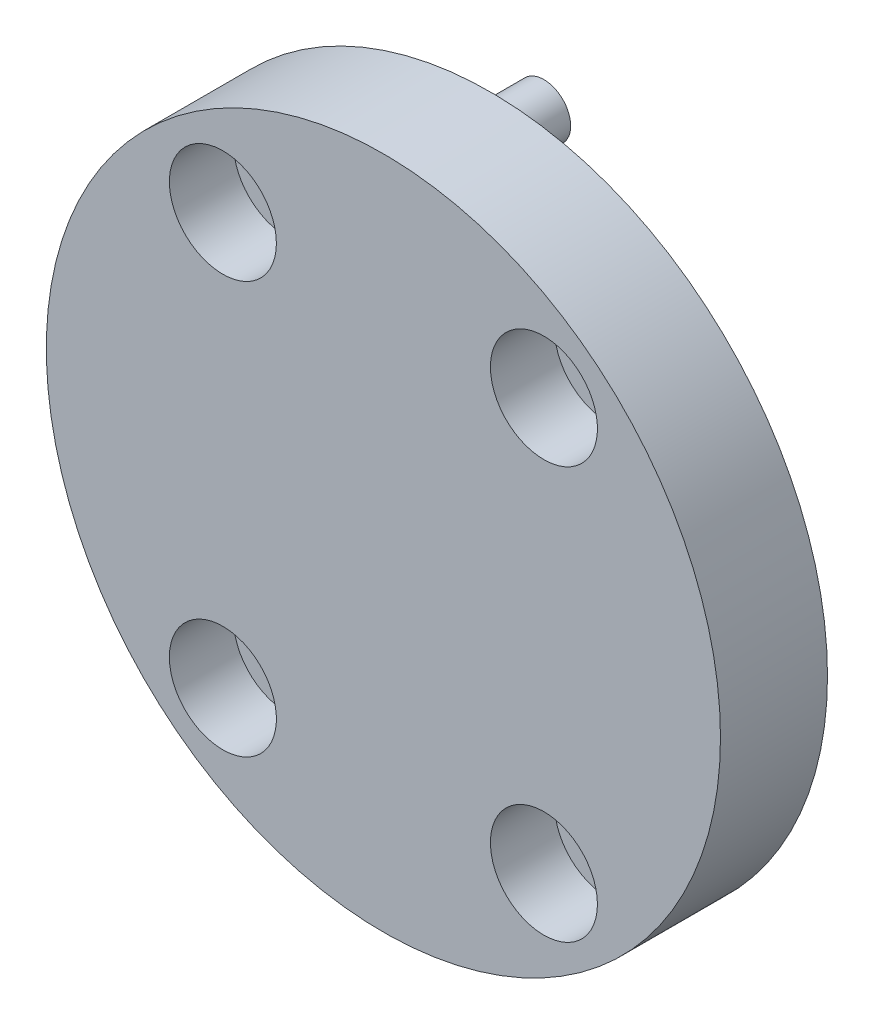
from build123d import *

# Parameters (mm, degrees)
SKETCH1_R           = 31.5
BOSS_EXTRUDE1_DEPTH = 5
SKETCH2_R           = 3
CUT_EXTRUDE1_DEPTH  = 46.656324863
SKETCH2_4_R         = 2.5
BOSS_EXTRUDE2_DEPTH = 15
SKETCH2_5_R         = 5
CUT_EXTRUDE2_DEPTH  = 6


with BuildPart() as part:
    # Sketch1 → Boss-Extrude1 (new, symmetric)
    with BuildSketch(Plane.XY):
        Circle(SKETCH1_R)
    extrude(amount=BOSS_EXTRUDE1_DEPTH, both=True)

    # Sketch2 → Cut-Extrude1 (cut, through all)
    with BuildSketch(Plane.XY.offset(5)):
        with Locations((-15, 19.242640687)):
            Circle(SKETCH2_R)
        with Locations((-15, -19.242640687)):
            Circle(SKETCH2_R)
        with Locations((15, -19.242640687)):
            Circle(SKETCH2_R)
        with Locations((15, 19.242640687)):
            Circle(SKETCH2_R)
    extrude(amount=-CUT_EXTRUDE1_DEPTH, mode=Mode.SUBTRACT)

    # Sketch2_4 → Boss-Extrude2 (add)
    with BuildSketch(Plane.XY.offset(5)):
        with Locations((0, 27.5)):
            Circle(SKETCH2_4_R)
    extrude(amount=-BOSS_EXTRUDE2_DEPTH)

    # Sketch2_5 → Cut-Extrude2 (cut)
    with BuildSketch(Plane.XY.offset(5)):
        with Locations((-15, 19.242640687)):
            Circle(SKETCH2_5_R)
        with Locations((-15, -19.242640687)):
            Circle(SKETCH2_5_R)
        with Locations((15, -19.242640687)):
            Circle(SKETCH2_5_R)
        with Locations((15, 19.242640687)):
            Circle(SKETCH2_5_R)
    extrude(amount=-CUT_EXTRUDE2_DEPTH, mode=Mode.SUBTRACT)


solid = part.part
